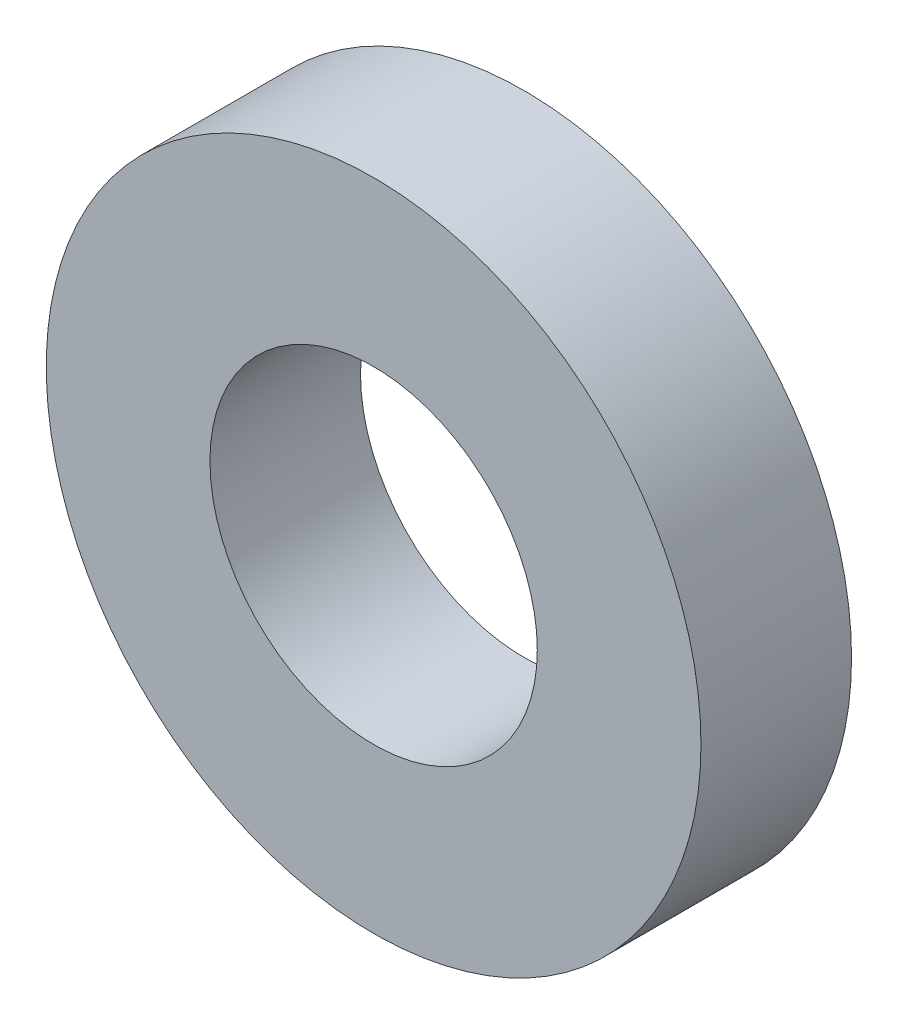
from build123d import *

# Parameters (mm, degrees)
SKETCH1_R           = 3
SKETCH1_R_2         = 1.5
BOSS_EXTRUDE1_DEPTH = 1.38


with BuildPart() as part:
    # Sketch1 → Boss-Extrude1 (new body)
    with BuildSketch(Plane.XY):
        Circle(SKETCH1_R)
        Circle(SKETCH1_R_2, mode=Mode.SUBTRACT)
    extrude(amount=BOSS_EXTRUDE1_DEPTH)


solid = part.part
